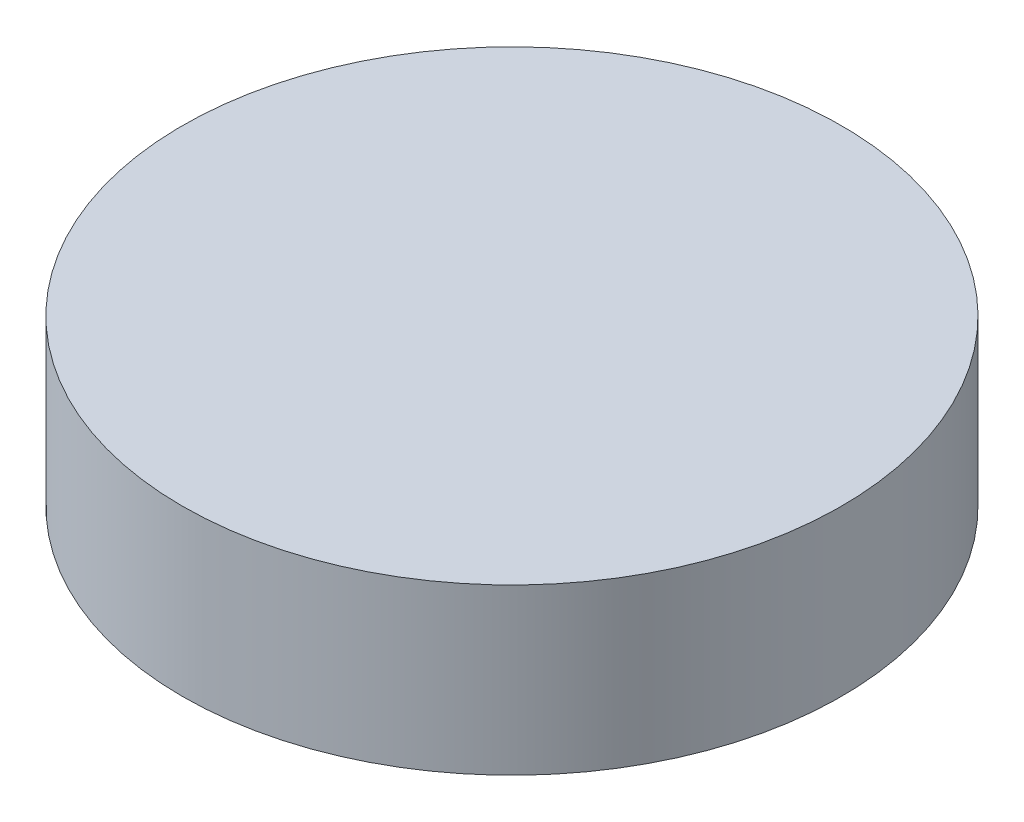
from build123d import *

# Parameters (mm, degrees)
SKETCH1_R           = 20
BOSS_EXTRUDE1_DEPTH = 10
SKETCH2_R           = 5
CUT_EXTRUDE1_DEPTH  = 5


with BuildPart() as part:
    # Sketch1 → Boss-Extrude1 (new body)
    with BuildSketch(Plane(origin=(0, 0, 0), x_dir=(1, 0, 0), z_dir=(0, 1, 0))):
        Circle(SKETCH1_R)
    extrude(amount=BOSS_EXTRUDE1_DEPTH)

    # Sketch2 → Cut-Extrude1 (cut)
    with BuildSketch(Plane(origin=(0, 0, 0), x_dir=(1, 0, 0), z_dir=(0, 1, 0))):
        Circle(SKETCH2_R)
    extrude(amount=CUT_EXTRUDE1_DEPTH, mode=Mode.SUBTRACT)


solid = part.part
